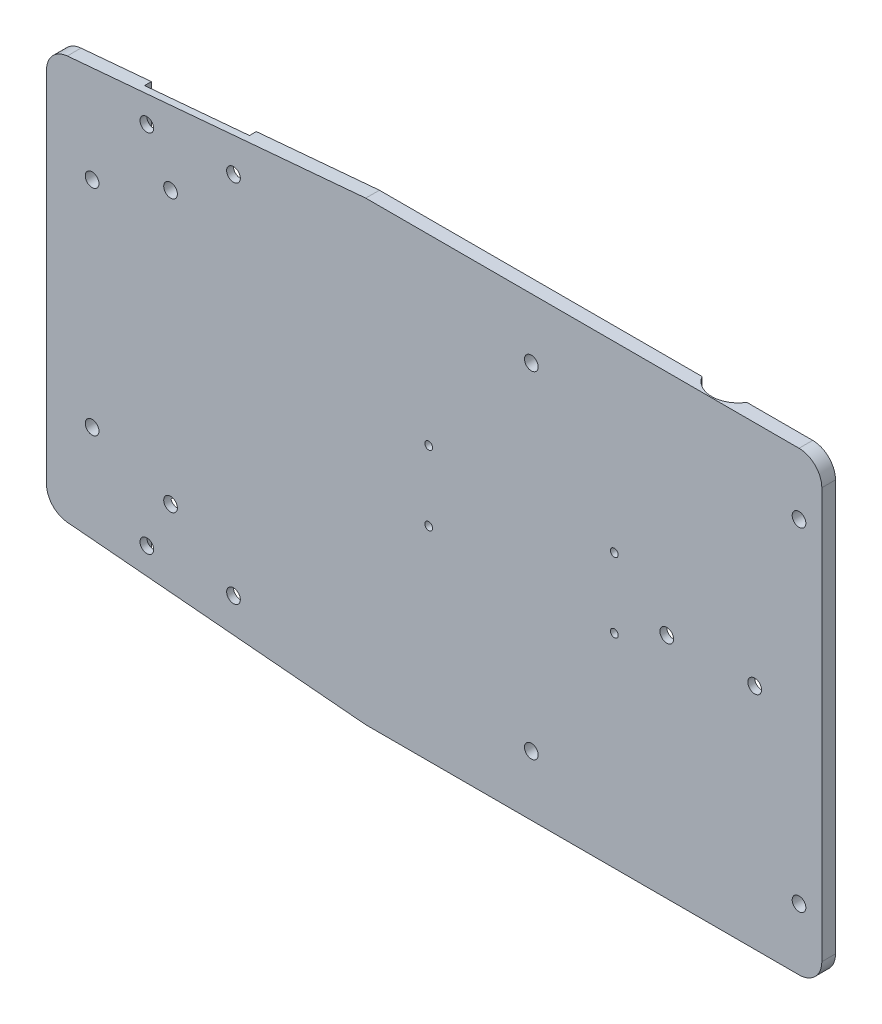
from build123d import *

# Parameters (mm, degrees)
BOSS_EXTRUDE1_DEPTH = 3
SKETCH2_R           = 1.5
CUT_EXTRUDE1_DEPTH  = 10
SKETCH6_W           = 23
SKETCH6_H           = 1.5
CUT_EXTRUDE2_DEPTH  = 20
SKETCH7_W           = 66.1
SKETCH7_H           = 41.35
CUT_EXTRUDE3_DEPTH  = 1.5
SKETCH9_R           = 0.85
CUT_EXTRUDE4_DEPTH  = 6.5
SKETCH10_W          = 43
SKETCH10_H          = 43
CUT_EXTRUDE5_DEPTH  = 1.5
SKETCH17_R          = 1.5
CUT_EXTRUDE11_DEPTH = 30.5
SKETCH18_R          = 1.5
CUT_EXTRUDE12_DEPTH = 30.5
SKETCH19_W          = 28
SKETCH19_H          = 41.645525892
CUT_EXTRUDE13_DEPTH = 1.5
SKETCH20_R          = 1.5
CUT_EXTRUDE14_DEPTH = 1.5
SKETCH21_R          = 1.5
CUT_EXTRUDE15_DEPTH = 10
SKETCH23_R          = 5.75
CUT_EXTRUDE16_DEPTH = 4


with BuildPart() as part:
    # Sketch1 → Boss-Extrude1 (new body)
    with BuildSketch(Plane.XY):
        with BuildLine():
            Line((-65.435778714, 44.275111174), (0, 50))
            Line((0, 50), (95, 50))
            ThreePointArc((95, 50), (98.535533906, 48.535533906), (100, 45))
            Line((100, 45), (100, -45))
            ThreePointArc((100, -45), (98.535533906, -48.535533906), (95, -50))
            Line((95, -50), (0, -50))
            Line((0, -50), (-65.435778714, -44.275111174))
            ThreePointArc((-65.435778714, -44.275111174), (-68.686386684, -42.672088721), (-70, -39.294137683))
            Line((-70, -39.294137683), (-70, 39.294137683))
            ThreePointArc((-70, 39.294137683), (-68.686386684, 42.672088721), (-65.435778714, 44.275111174))
        make_face()
    extrude(amount=BOSS_EXTRUDE1_DEPTH)

    # Sketch2 → Cut-Extrude1 (cut)
    with BuildSketch(Plane.XY.offset(3)):
        with Locations((-48, -40)):
            Circle(SKETCH2_R)
        with Locations((-29, -40)):
            Circle(SKETCH2_R)
        with Locations((-48, 40)):
            Circle(SKETCH2_R)
        with Locations((-29, 40)):
            Circle(SKETCH2_R)
    extrude(amount=-CUT_EXTRUDE1_DEPTH, mode=Mode.SUBTRACT)

    # Sketch6 → Cut-Extrude2 (cut)
    with BuildSketch(Plane(origin=(0, 50, 0), x_dir=(1, 0, 0), z_dir=(0, 1, 0))):
        with Locations((-38.5, -0.75)):
            Rectangle(SKETCH6_W, SKETCH6_H)
    cut_extrude2 = extrude(amount=-CUT_EXTRUDE2_DEPTH, mode=Mode.SUBTRACT)

    # Sketch7 → Cut-Extrude3 (cut)
    with BuildSketch(Plane(origin=(0, 0, 0), x_dir=(-1, 0, 0), z_dir=(0, 0, -1))):
        with Locations((-27.95, 0)):
            Rectangle(SKETCH7_W, SKETCH7_H)
    extrude(amount=-CUT_EXTRUDE3_DEPTH, mode=Mode.SUBTRACT)

    # Sketch9 → Cut-Extrude4 (cut)
    with BuildSketch(Plane(origin=(0, 0, 0), x_dir=(-1, 0, 0), z_dir=(0, 0, -1))):
        with Locations((-54.5, 9.925)):
            Circle(SKETCH9_R)
        with Locations((-54.5, -5.375)):
            Circle(SKETCH9_R)
        with Locations((-13.8, 9.925)):
            Circle(SKETCH9_R)
        with Locations((-13.8, -5.375)):
            Circle(SKETCH9_R)
    extrude(amount=-CUT_EXTRUDE4_DEPTH, mode=Mode.SUBTRACT)

    # Sketch10 → Cut-Extrude5 (cut)
    with BuildSketch(Plane(origin=(0, 0, 0), x_dir=(-1, 0, 0), z_dir=(0, 0, -1))):
        with Locations((28.6, 0)):
            Rectangle(SKETCH10_W, SKETCH10_H)
    extrude(amount=-CUT_EXTRUDE5_DEPTH, mode=Mode.SUBTRACT)

    # Mirror1: Cut-Extrude2 across plane
    add(cut_extrude2.mirror(Plane.ZX), mode=Mode.SUBTRACT)

    # Sketch17 → Cut-Extrude11 (cut)
    with BuildSketch(Plane(origin=(0, 0, 0), x_dir=(-1, 0, 0), z_dir=(0, 0, -1))):
        with Locations((-36.309541126, -36.85)):
            Circle(SKETCH17_R)
        with Locations((-36.309541126, 36.85)):
            Circle(SKETCH17_R)
    extrude(amount=-CUT_EXTRUDE11_DEPTH, mode=Mode.SUBTRACT)

    # Sketch18 → Cut-Extrude12 (cut)
    with BuildSketch(Plane(origin=(0, 0, 0), x_dir=(-1, 0, 0), z_dir=(0, 0, -1))):
        with Locations((-95, -36.5)):
            Circle(SKETCH18_R)
        with Locations((-95, 36.5)):
            Circle(SKETCH18_R)
        with Locations((60, -23.5)):
            Circle(SKETCH18_R)
        with Locations((60, 23.5)):
            Circle(SKETCH18_R)
    extrude(amount=-CUT_EXTRUDE12_DEPTH, mode=Mode.SUBTRACT)

    # Sketch19 → Cut-Extrude13 (cut)
    with BuildSketch(Plane(origin=(0, 0, 0), x_dir=(-1, 0, 0), z_dir=(0, 0, -1))):
        with Locations((-76, 0)):
            Rectangle(SKETCH19_W, SKETCH19_H)
    extrude(amount=-CUT_EXTRUDE13_DEPTH, mode=Mode.SUBTRACT)

    # Sketch20 → Cut-Extrude14 (cut)
    with BuildSketch(Plane(origin=(0, 0, 1.5), x_dir=(-1, 0, 0), z_dir=(0, 0, -1))):
        with Locations((-66, 0)):
            Circle(SKETCH20_R)
        with Locations((-85.28, 0)):
            Circle(SKETCH20_R)
    extrude(amount=-CUT_EXTRUDE14_DEPTH, mode=Mode.SUBTRACT)

    # Sketch21 → Cut-Extrude15 (cut)
    with BuildSketch(Plane.XY.offset(3)):
        with Locations((-42.8, 30.1)):
            Circle(SKETCH21_R)
        with Locations((-42.8, -29.5)):
            Circle(SKETCH21_R)
    extrude(amount=-CUT_EXTRUDE15_DEPTH, mode=Mode.SUBTRACT)

    # Sketch23 → Cut-Extrude16 (cut)
    with BuildSketch(Plane(origin=(0, 50, 0), x_dir=(1, 0, 0), z_dir=(0, 1, 0))):
        with Locations((75.64, 3)):
            Circle(SKETCH23_R)
    cut_extrude16 = extrude(amount=-CUT_EXTRUDE16_DEPTH, mode=Mode.SUBTRACT)

    # Mirror2: Cut-Extrude16 across plane
    add(cut_extrude16.mirror(Plane.ZX), mode=Mode.SUBTRACT)


solid = part.part
